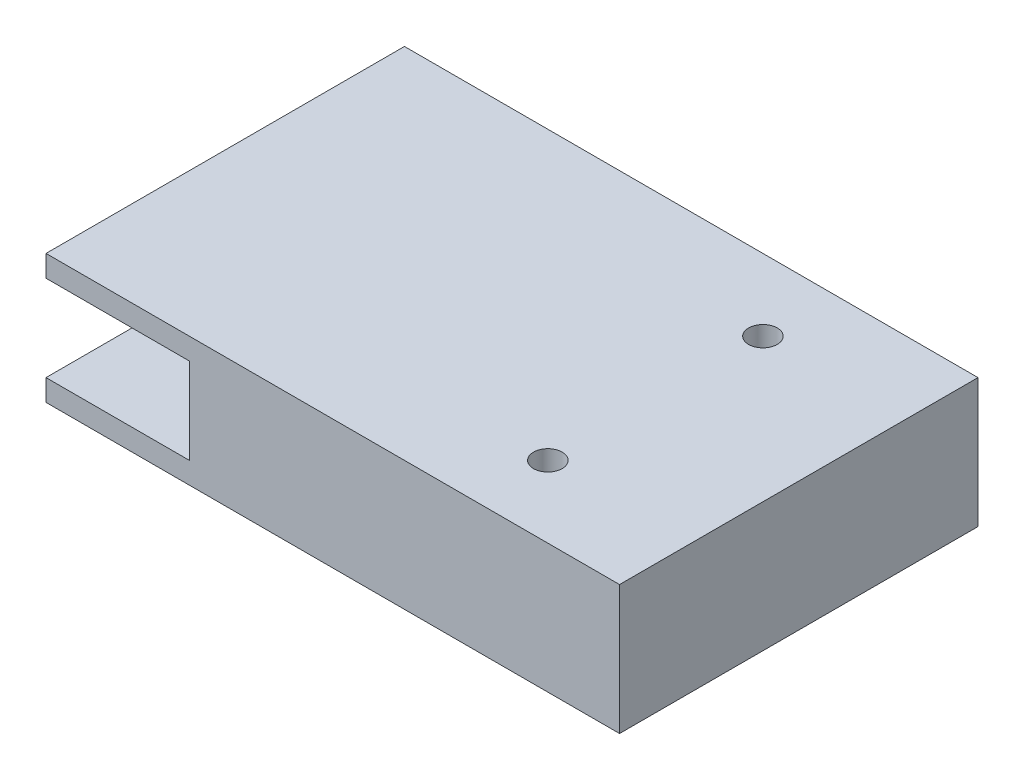
from build123d import *

# Parameters (mm, degrees)
SKETCH1_W           = 80
SKETCH1_H           = 50
BOSS_EXTRUDE1_DEPTH = 3
SKETCH2_R           = 2
BOSS_EXTRUDE2_DEPTH = 14
SKETCH3_W           = 60
SKETCH3_H           = 50
BOSS_EXTRUDE3_DEPTH = 12
SKETCH4_R           = 3
CUT_EXTRUDE1_DEPTH  = 10
SKETCH5_W           = 80
SKETCH5_H           = 50
BOSS_EXTRUDE4_DEPTH = 3
SKETCH6_R           = 2
CUT_EXTRUDE2_DEPTH  = 49
BOSS_EXTRUDE5_DEPTH = 3
SKETCH8_R           = 1
BOSS_EXTRUDE6_DEPTH = 2


with BuildPart() as part:
    # Sketch1 → Boss-Extrude1 (new body)
    with BuildSketch(Plane(origin=(0, 0, 0), x_dir=(1, 0, 0), z_dir=(0, 1, 0))):
        Rectangle(SKETCH1_W, SKETCH1_H)
    extrude(amount=BOSS_EXTRUDE1_DEPTH)

    # Sketch2 → Boss-Extrude2 (add)
    with BuildSketch(Plane(origin=(0, 3, 0), x_dir=(1, 0, 0), z_dir=(0, 1, 0))):
        with Locations((-30, 11)):
            Circle(SKETCH2_R)
        with Locations((-30, -11)):
            Circle(SKETCH2_R)
    extrude(amount=BOSS_EXTRUDE2_DEPTH)

    # Sketch3 → Boss-Extrude3 (add)
    with BuildSketch(Plane(origin=(0, 3, 0), x_dir=(1, 0, 0), z_dir=(0, 1, 0))):
        with Locations((10, 0)):
            Rectangle(SKETCH3_W, SKETCH3_H)
    extrude(amount=BOSS_EXTRUDE3_DEPTH)

    # Sketch4 → Cut-Extrude1 (cut)
    with BuildSketch(Plane.ZY.offset(20)):
        with Locations((0, 11)):
            Circle(SKETCH4_R)
    extrude(amount=-CUT_EXTRUDE1_DEPTH, mode=Mode.SUBTRACT)

    # Sketch5 → Boss-Extrude4 (add)
    with BuildSketch(Plane(origin=(0, 15, 0), x_dir=(1, 0, 0), z_dir=(0, 1, 0))):
        Rectangle(SKETCH5_W, SKETCH5_H)
    extrude(amount=BOSS_EXTRUDE4_DEPTH)

    # Sketch6 → Cut-Extrude2 (cut)
    with BuildSketch(Plane(origin=(0, 18, 0), x_dir=(1, 0, 0), z_dir=(0, 1, 0))):
        with Locations((20, 15)):
            Circle(SKETCH6_R)
        with Locations((20, -15)):
            Circle(SKETCH6_R)
    extrude(amount=-CUT_EXTRUDE2_DEPTH, mode=Mode.SUBTRACT)

    # Sketch7 → Boss-Extrude5 (add)
    with BuildSketch(Plane(origin=(0, 0, -25), x_dir=(-1, 0, 0), z_dir=(0, 0, -1))):
        Polygon((15, 11.309401077), (13, 10.154700538), (13, 7.845299462), (15, 6.690598923), (17, 7.845299462), (17, 10.154700538), align=None)
        Polygon((5, 11.309401077), (3, 10.154700538), (3, 7.845299462), (5, 6.690598923), (7, 7.845299462), (7, 10.154700538), align=None)
    extrude(amount=BOSS_EXTRUDE5_DEPTH)

    # Sketch8 → Boss-Extrude6 (add)
    with BuildSketch(Plane(origin=(0, 0, -28), x_dir=(-1, 0, 0), z_dir=(0, 0, -1))):
        with Locations((14.883913009, 9)):
            Circle(SKETCH8_R)
        with Locations((5, 9)):
            Circle(SKETCH8_R)
    extrude(amount=BOSS_EXTRUDE6_DEPTH)


solid = part.part
